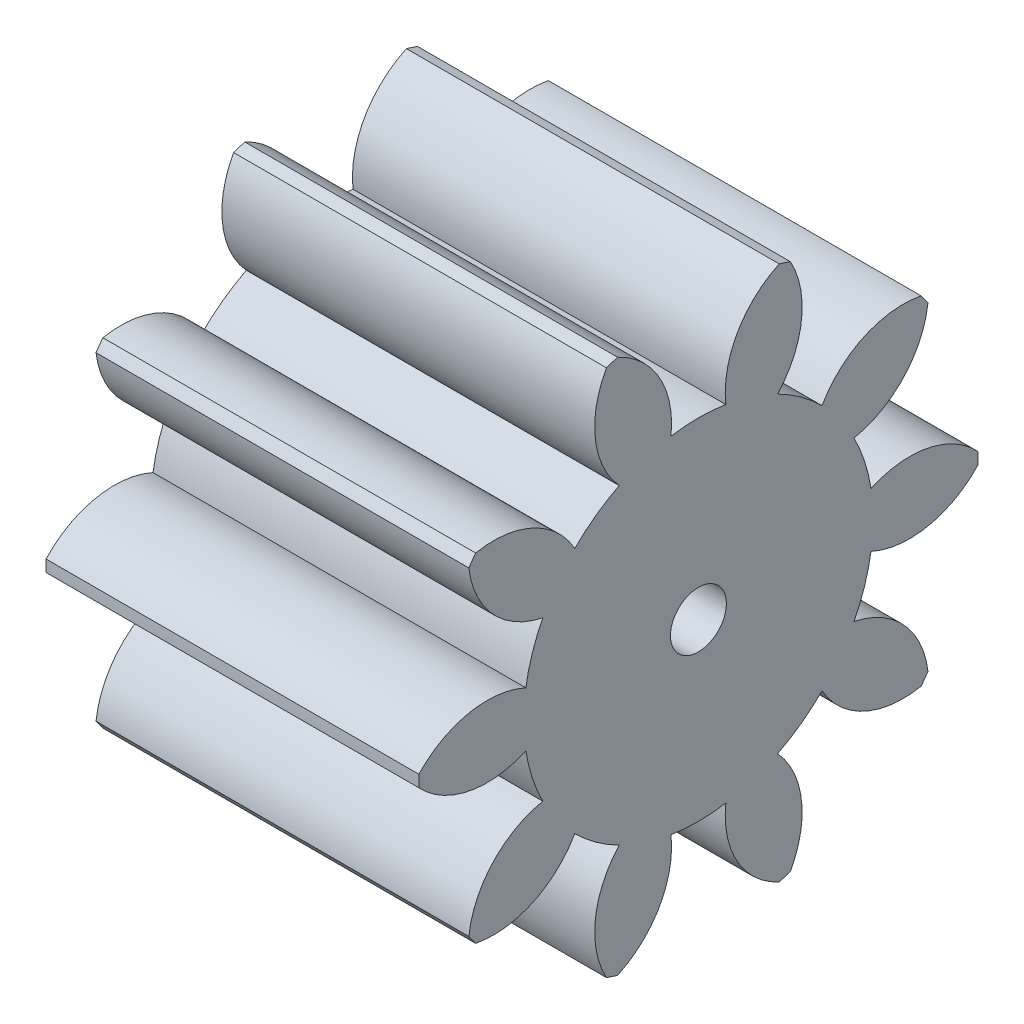
from build123d import *

# Parameters (mm, degrees)
BASPROSKE_W     = 20
BASPROSKE_H     = 15
TOOTHCUT_DEPTH  = 30.154759474
TEETHCUTS_COUNT = 10
TEETHCUTS_ANGLE = 324
BORSKE_R        = 1.5
BORE_DEPTH      = 50.0000508


with BuildPart() as part:
    # BasProSke → Base-Revolve (revolve)
    with BuildSketch(Plane(origin=(0, 0, 0), x_dir=(1, 0, 0), z_dir=(0, 1, 0)), mode=Mode.PRIVATE) as base_revolve_sk:
        with Locations((10, 7.5)):
            Rectangle(BASPROSKE_W, BASPROSKE_H)
    revolve(base_revolve_sk.sketch.rotate(Axis((-10, 0, 0), (1, 0, 0)), 180), axis=Axis((-10, 0, 0), (1, 0, 0)))

    # TooCutSke → ToothCut (cut, through all)
    with BuildSketch(Plane(origin=(0, 0, 0), x_dir=(0, 0, -1), z_dir=(1, 0, 0))):
        with BuildLine():
            ThreePointArc((1.471305988, 9.25781479), (0, 9.374), (-1.471305988, 9.25781479))
            ThreePointArc((-1.471305988, 9.25781479), (-2.088583433, 12.288176173), (-4.370236495, 14.375801826))
            ThreePointArc((-4.370236495, 14.375801826), (0, 15.0254), (4.370236495, 14.375801826))
            ThreePointArc((4.370236495, 14.375801826), (2.088583433, 12.288176173), (1.471305988, 9.25781479))
        make_face()
    toothcut = extrude(amount=TOOTHCUT_DEPTH, mode=Mode.SUBTRACT)

    # TeethCuts: ToothCut ×10 about axis
    teethcuts_axis = Axis((-10, 0, 0), (1, 0, 0))
    for i in range(1, TEETHCUTS_COUNT):
        add(toothcut.rotate(teethcuts_axis, i * TEETHCUTS_ANGLE / (TEETHCUTS_COUNT - 1)), mode=Mode.SUBTRACT)

    # BorSke → Bore (cut, symmetric)
    with BuildSketch(Plane(origin=(0, 0, 0), x_dir=(0, 0, -1), z_dir=(1, 0, 0))):
        with Locations(Location((0, 0, 0), (0, 0, 180))):
            Circle(BORSKE_R)
    extrude(amount=BORE_DEPTH, both=True, mode=Mode.SUBTRACT)


solid = part.part
